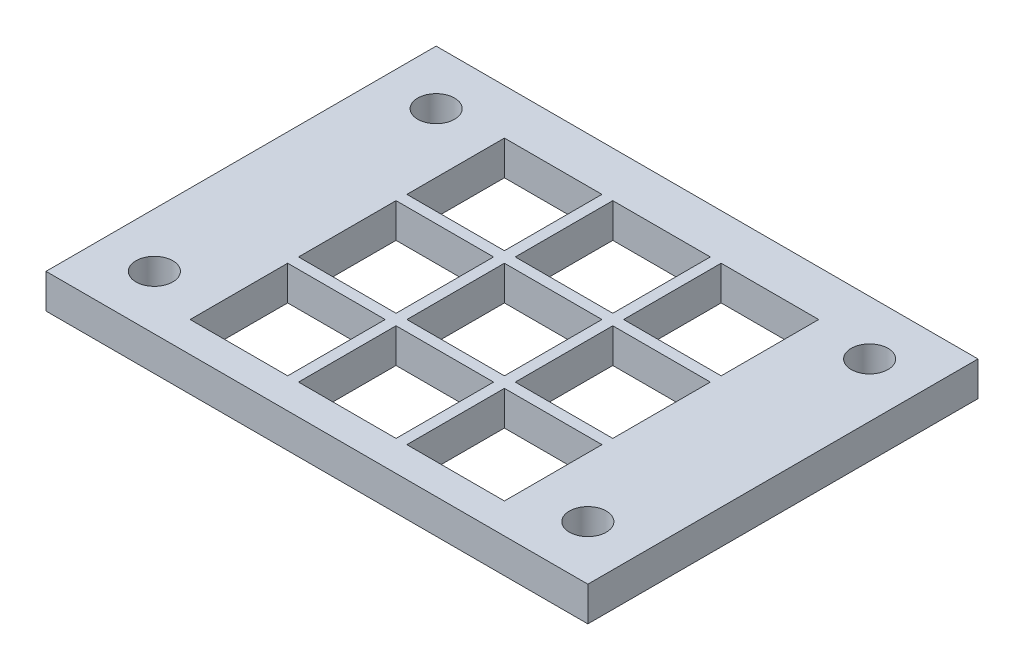
from build123d import *

# Parameters (mm, degrees)
SKETCH1_W           = 50
SKETCH1_H           = 36
SKETCH1_R           = 1.7
SKETCH1_W_2         = 9
SKETCH1_H_2         = 9
BOSS_EXTRUDE1_DEPTH = 3.175


with BuildPart() as part:
    # Sketch1 → Boss-Extrude1 (new body)
    with BuildSketch(Plane(origin=(0, 0, 0), x_dir=(1, 0, 0), z_dir=(0, 1, 0))):
        with Locations((25, 18)):
            Rectangle(SKETCH1_W, SKETCH1_H)
        with Locations((5, 5)):
            Circle(SKETCH1_R, mode=Mode.SUBTRACT)
        with Locations((5, 31)):
            Circle(SKETCH1_R, mode=Mode.SUBTRACT)
        with Locations((45, 31)):
            Circle(SKETCH1_R, mode=Mode.SUBTRACT)
        with Locations((45, 5)):
            Circle(SKETCH1_R, mode=Mode.SUBTRACT)
        with Locations((15, 7.3)):
            Rectangle(SKETCH1_W_2, SKETCH1_H_2, mode=Mode.SUBTRACT)
        with Locations((25, 7.3)):
            Rectangle(SKETCH1_W_2, SKETCH1_H_2, mode=Mode.SUBTRACT)
        with Locations((35, 7.3)):
            Rectangle(SKETCH1_W_2, SKETCH1_H_2, mode=Mode.SUBTRACT)
        with Locations((25, 17.3)):
            Rectangle(SKETCH1_W_2, SKETCH1_H_2, mode=Mode.SUBTRACT)
        with Locations((35, 17.3)):
            Rectangle(SKETCH1_W_2, SKETCH1_H_2, mode=Mode.SUBTRACT)
        with Locations((25, 27.3)):
            Rectangle(SKETCH1_W_2, SKETCH1_H_2, mode=Mode.SUBTRACT)
        with Locations((35, 27.3)):
            Rectangle(SKETCH1_W_2, SKETCH1_H_2, mode=Mode.SUBTRACT)
        with Locations((15, 17.3)):
            Rectangle(SKETCH1_W_2, SKETCH1_H_2, mode=Mode.SUBTRACT)
        with Locations((15, 27.3)):
            Rectangle(SKETCH1_W_2, SKETCH1_H_2, mode=Mode.SUBTRACT)
    extrude(amount=BOSS_EXTRUDE1_DEPTH)


solid = part.part
